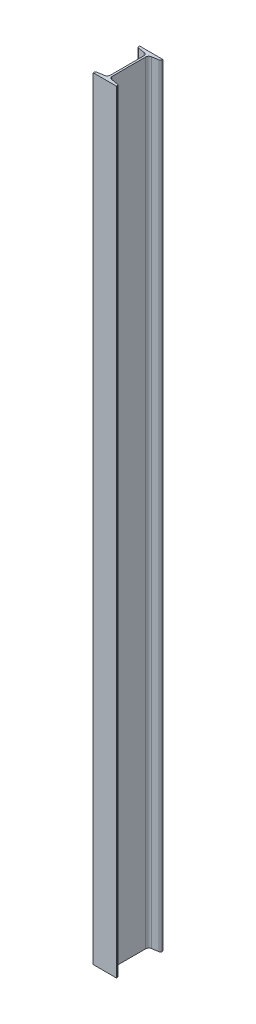
from build123d import *

# Parameters (mm, degrees)
SB_BEAM_120_X_12_1_DEPTH = 2000


with BuildPart() as part:
    # Sketch15 → Sb beam 120 X 12(1) (new body)
    with BuildSketch(Plane(origin=(0, 0, 0), x_dir=(-1, 0, 0), z_dir=(0, 1, 0))):
        with BuildLine():
            Line((-30, -60), (-30, -58.080070835))
            ThreePointArc((-30, -58.080070835), (-29.052095223, -55.494589303), (-26.657642624, -54.134502919))
            Line((-26.657642624, -54.134502919), (-9.184714752, -51.222135832))
            ThreePointArc((-9.184714752, -51.222135832), (-4.395809555, -48.501963064), (-2.5, -43.331))
            Line((-2.5, -43.331), (-2.5, 43.331))
            ThreePointArc((-2.5, 43.331), (-4.395809555, 48.501963064), (-9.184714752, 51.222135832))
            Line((-9.184714752, 51.222135832), (-26.657642624, 54.134502919))
            ThreePointArc((-26.657642624, 54.134502919), (-29.052095223, 55.494589303), (-30, 58.080070835))
            Line((-30, 58.080070835), (-30, 60))
            Line((-30, 60), (30, 60))
            Line((30, 60), (30, 58.080070835))
            ThreePointArc((30, 58.080070835), (29.052095223, 55.494589303), (26.657642624, 54.134502919))
            Line((26.657642624, 54.134502919), (9.184714752, 51.222135832))
            ThreePointArc((9.184714752, 51.222135832), (4.395809555, 48.501963064), (2.5, 43.331))
            Line((2.5, 43.331), (2.5, -43.331))
            ThreePointArc((2.5, -43.331), (4.395809555, -48.501963064), (9.184714752, -51.222135832))
            Line((9.184714752, -51.222135832), (26.657642624, -54.134502919))
            ThreePointArc((26.657642624, -54.134502919), (29.052095223, -55.494589303), (30, -58.080070835))
            Line((30, -58.080070835), (30, -60))
            Line((30, -60), (-30, -60))
        make_face()
    extrude(amount=SB_BEAM_120_X_12_1_DEPTH)


solid = part.part
